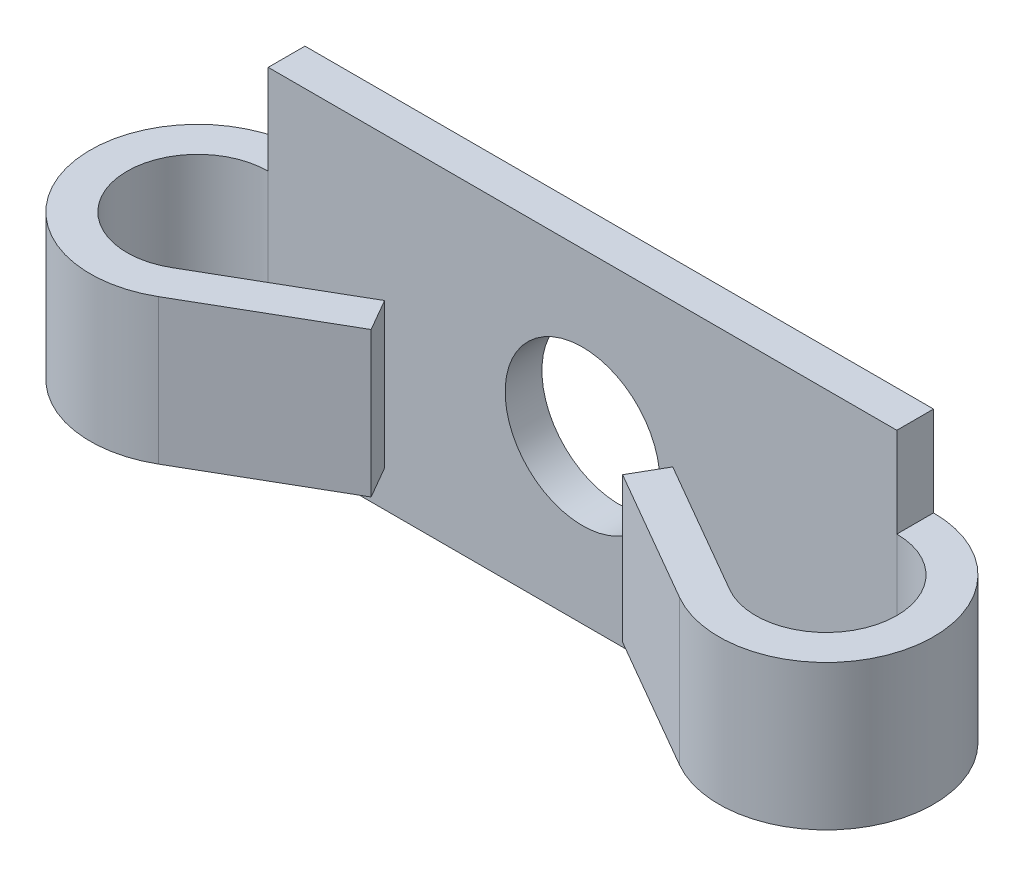
from build123d import *

# Parameters (mm, degrees)
SKETCH_1_W      = 32.5
SKETCH_1_H      = 16.8
SKETCH_1_R      = 4
EXTRUDE_1_DEPTH = 1.9
EXTRUDE_2_DEPTH = 3.75


with BuildPart() as part:
    # Эскиз1 → Бобышка-Вытянуть1 (new body)
    with BuildSketch(Plane.XY):
        Rectangle(SKETCH_1_W, SKETCH_1_H)
        Circle(SKETCH_1_R, mode=Mode.SUBTRACT)
    extrude(amount=EXTRUDE_1_DEPTH)

    # Эскиз3 → Бобышка-Вытянуть2 (add, symmetric)
    with BuildSketch(Plane(origin=(0, 0, 0), x_dir=(1, 0, 0), z_dir=(0, 1, 0))):
        with BuildLine():
            Line((-14.425, -8.710992724), (-7.45, -4.683974596))
            Line((-7.45, -4.683974596), (-6.5, -6.329422863))
            Line((-6.5, -6.329422863), (-13.475, -10.356440991))
            ThreePointArc((-13.475, -10.356440991), (-21.610888336, -6.9864457), (-16.25, 0))
            Line((-16.25, 0), (-16.25, -1.9))
            ThreePointArc((-16.25, -1.9), (-19.775629266, -6.494689515), (-14.425, -8.710992724))
        make_face()
    extrude_2 = extrude(amount=EXTRUDE_2_DEPTH, both=True)

    # Зеркальное отражение1: Бобышка-Вытянуть2 across plane
    add(extrude_2.mirror(Plane(origin=(0, 0, 0), x_dir=(0, 0, 1), z_dir=(1, 0, 0))))


solid = part.part
